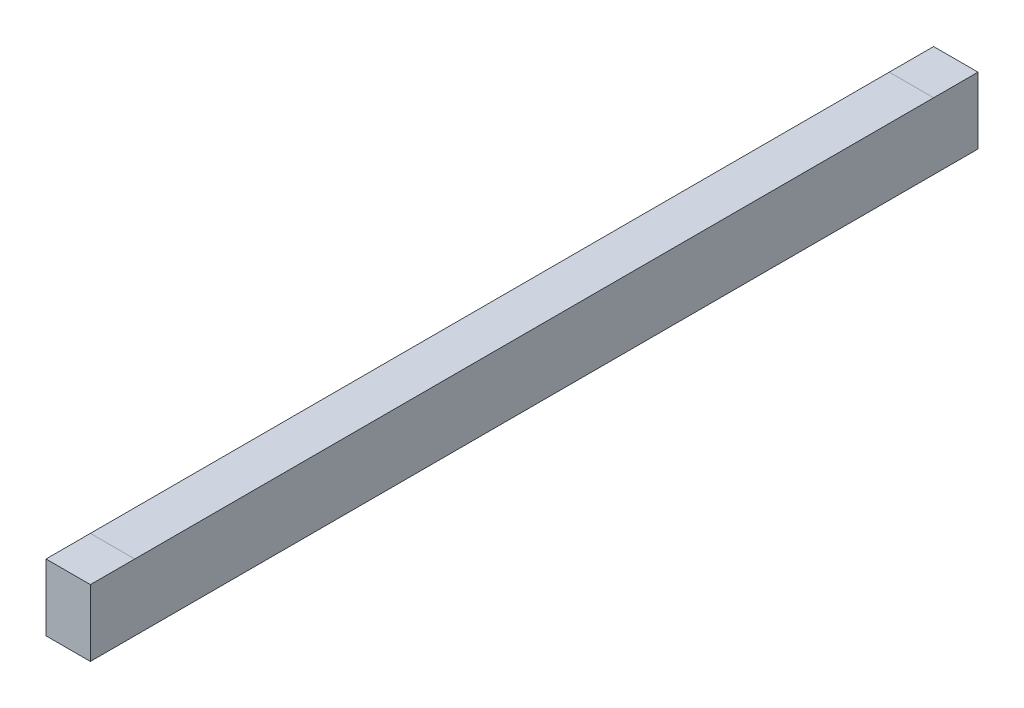
from build123d import *

# Parameters (mm, degrees)
SKETCH1_W           = 100
SKETCH1_H           = 150
BOSS_EXTRUDE1_DEPTH = 2000


with BuildPart() as part:
    # Sketch1 → Boss-Extrude1 (new body)
    with BuildSketch(Plane.XY):
        with Locations((50, 75)):
            Rectangle(SKETCH1_W, SKETCH1_H)
    extrude(amount=BOSS_EXTRUDE1_DEPTH)


solid = part.part
